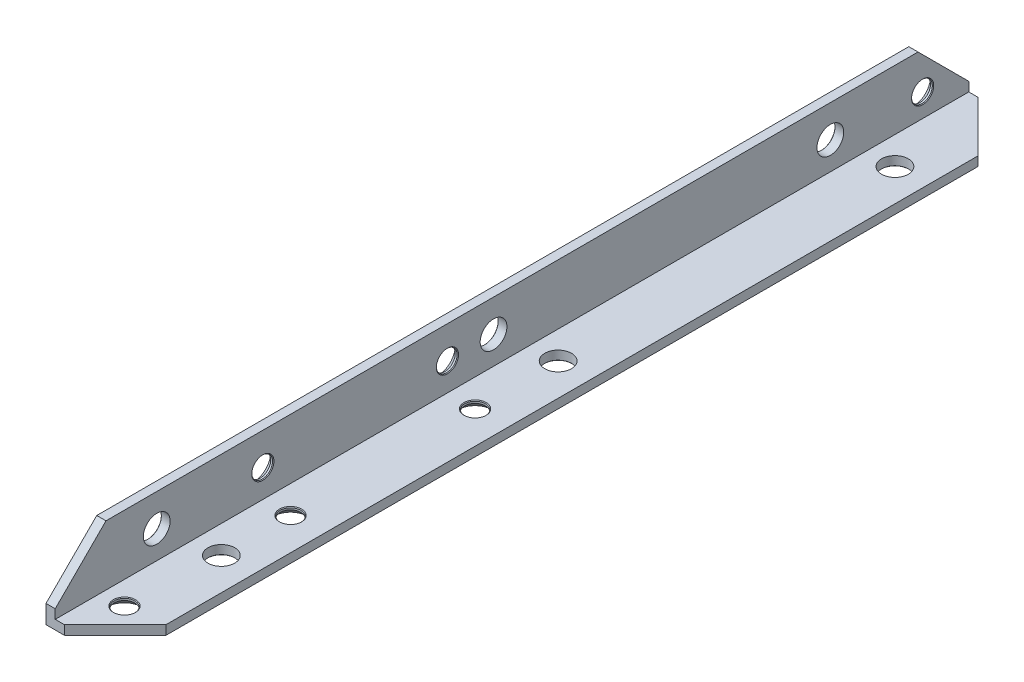
from build123d import *

# Parameters (mm, degrees)
EXTRUDE_1_DEPTH             = 198
CHAMFER_1_SIZE              = 11
HOLE_WIZARD_M41_AT_2_COUNT  = 2
HOLE_WIZARD_M41_AT_2_PITCH  = 35.0142828
HOLE_WIZARD_M41_AT_3_COUNT  = 2
HOLE_WIZARD_M41_AT_3_PITCH  = 75.00666637
HOLE_WIZARD_M42_AT_2_COUNT  = 2
HOLE_WIZARD_M42_AT_2_PITCH  = 103.004854255
HOLE_WIZARD_M42_AT_3_COUNT  = 2
HOLE_WIZARD_M42_AT_3_PITCH  = 143.003496461
HOLE_WIZARD_M51_D           = 5.8
HOLE_WIZARD_M51_DEPTH       = 3
HOLE_WIZARD_M51_CSINK_D     = 6
HOLE_WIZARD_M51_CSINK_ANGLE = 90
HOLE_WIZARD_M51_TIP         = 1.742495795
HOLE_WIZARD_M52_D           = 5.8
HOLE_WIZARD_M52_DEPTH       = 3
HOLE_WIZARD_M52_CSINK_D     = 6
HOLE_WIZARD_M52_CSINK_ANGLE = 90
HOLE_WIZARD_M52_TIP         = 1.742495795


with BuildPart() as part:
    # Эскиз1 → Бобышка-Вытянуть1 (new body)
    with BuildSketch(Plane.XY):
        Polygon((0, 0), (0, 15), (2, 15), (2, 2), (15, 2), (15, 0), align=None)
    extrude(amount=EXTRUDE_1_DEPTH)

    # Фаска1
    chamfer_1_edges = [part.edges().sort_by_distance(p)[0] for p in [
        (1, 15, 198),
        (1, 15, 0),
        (15, 1, 198),
        (15, 1, 0),
    ]]
    chamfer(chamfer_1_edges, length=CHAMFER_1_SIZE)

    # Эскиз2 → Зенковка для винта с потайной головкой M41 (revolve, cut)
    with BuildSketch(Plane(origin=(7, 0, 188), x_dir=(0, 0, -1), z_dir=(1, 0, 0))):
        Polygon((0, 0), (0, 2), (2.4, 2), (2.25, 1.85), (2.25, 1.45), (3.7, 0), align=None)
    hole_wizard_m41 = revolve(axis=Axis((7, -6.35, 188), (0, 1, 0)), mode=Mode.SUBTRACT)

    # Зенковка для винта с потайной головкой M41 at 2: Зенковка для винта с потайной головкой M41 ×2
    with Locations(*[Vector(0.028559774, 0, -0.999592086) * (i * HOLE_WIZARD_M41_AT_2_PITCH) for i in range(1, HOLE_WIZARD_M41_AT_2_COUNT)]):
        add(hole_wizard_m41, mode=Mode.SUBTRACT)

    # Зенковка для винта с потайной головкой M41 at 3: Зенковка для винта с потайной головкой M41 ×2
    with Locations(*[Vector(0.013332148, 0, -0.999911123) * (i * HOLE_WIZARD_M41_AT_3_PITCH) for i in range(1, HOLE_WIZARD_M41_AT_3_COUNT)]):
        add(hole_wizard_m41, mode=Mode.SUBTRACT)

    # Эскиз4 → Зенковка для винта с потайной головкой M42 (revolve, cut)
    with BuildSketch(Plane(origin=(0, 7, 10), x_dir=(0, 0, 1), z_dir=(0, 1, 0))):
        Polygon((0, 0), (0, 2), (2.4, 2), (2.25, 1.85), (2.25, 1.45), (3.7, 0), align=None)
    hole_wizard_m42 = revolve(axis=Axis((-6.35, 7, 10), (1, 0, 0)), mode=Mode.SUBTRACT)

    # Зенковка для винта с потайной головкой M42 at 2: Зенковка для винта с потайной головкой M42 ×2
    with Locations(*[Vector(0, 0.00970828, 0.999952874) * (i * HOLE_WIZARD_M42_AT_2_PITCH) for i in range(1, HOLE_WIZARD_M42_AT_2_COUNT)]):
        add(hole_wizard_m42, mode=Mode.SUBTRACT)

    # Зенковка для винта с потайной головкой M42 at 3: Зенковка для винта с потайной головкой M42 ×2
    with Locations(*[Vector(0, 0.006992836, 0.99997555) * (i * HOLE_WIZARD_M42_AT_3_PITCH) for i in range(1, HOLE_WIZARD_M42_AT_3_COUNT)]):
        add(hole_wizard_m42, mode=Mode.SUBTRACT)

    # Отверстие с зазором M51
    with Locations(Plane.ZY):
        with Locations((103, 8), (30, 8), (176, 8)):
            CounterSinkHole(HOLE_WIZARD_M51_D / 2, HOLE_WIZARD_M51_CSINK_D / 2, depth=HOLE_WIZARD_M51_DEPTH, counter_sink_angle=HOLE_WIZARD_M51_CSINK_ANGLE)
            with Locations((0, 0, -(HOLE_WIZARD_M51_DEPTH + HOLE_WIZARD_M51_TIP / 2))):  # 118° drill point
                Cone(0, HOLE_WIZARD_M51_D / 2, HOLE_WIZARD_M51_TIP, mode=Mode.SUBTRACT)

    # Отверстие с зазором M52
    with Locations(Plane.XZ):
        with Locations((8, 95), (8, 22), (8, 168)):
            CounterSinkHole(HOLE_WIZARD_M52_D / 2, HOLE_WIZARD_M52_CSINK_D / 2, depth=HOLE_WIZARD_M52_DEPTH, counter_sink_angle=HOLE_WIZARD_M52_CSINK_ANGLE)
            with Locations((0, 0, -(HOLE_WIZARD_M52_DEPTH + HOLE_WIZARD_M52_TIP / 2))):  # 118° drill point
                Cone(0, HOLE_WIZARD_M52_D / 2, HOLE_WIZARD_M52_TIP, mode=Mode.SUBTRACT)


solid = part.part
